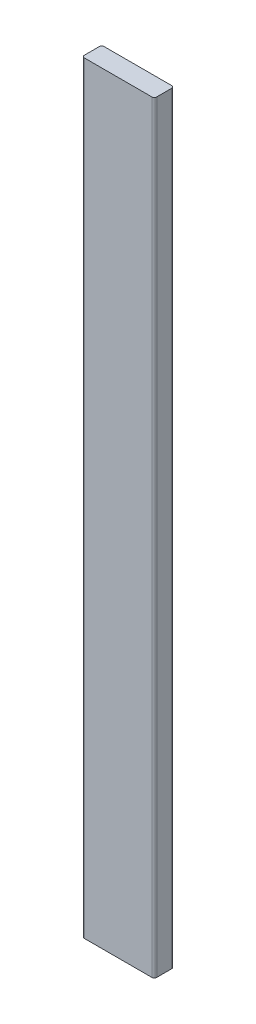
from build123d import *

# Parameters (mm, degrees)
SKETCH1_W           = 139.7
SKETCH1_H           = 1473.2
BOSS_EXTRUDE1_DEPTH = 38.1
FILLET1_R           = 4.7625


with BuildPart() as part:
    # Sketch1 → Boss-Extrude1 (new body)
    with BuildSketch(Plane.XY):
        with Locations((-274.782187925, 736.6)):
            Rectangle(SKETCH1_W, SKETCH1_H)
    extrude(amount=-BOSS_EXTRUDE1_DEPTH)

    # Fillet1
    fillet1_edges = [part.edges().sort_by_distance(p)[0] for p in [
        (-204.932187925, 736.6, 0),
        (-204.932187925, 736.6, -38.1),
        (-344.632187925, 736.6, -38.1),
        (-344.632187925, 736.6, 0),
    ]]
    fillet(fillet1_edges, radius=FILLET1_R)


solid = part.part
